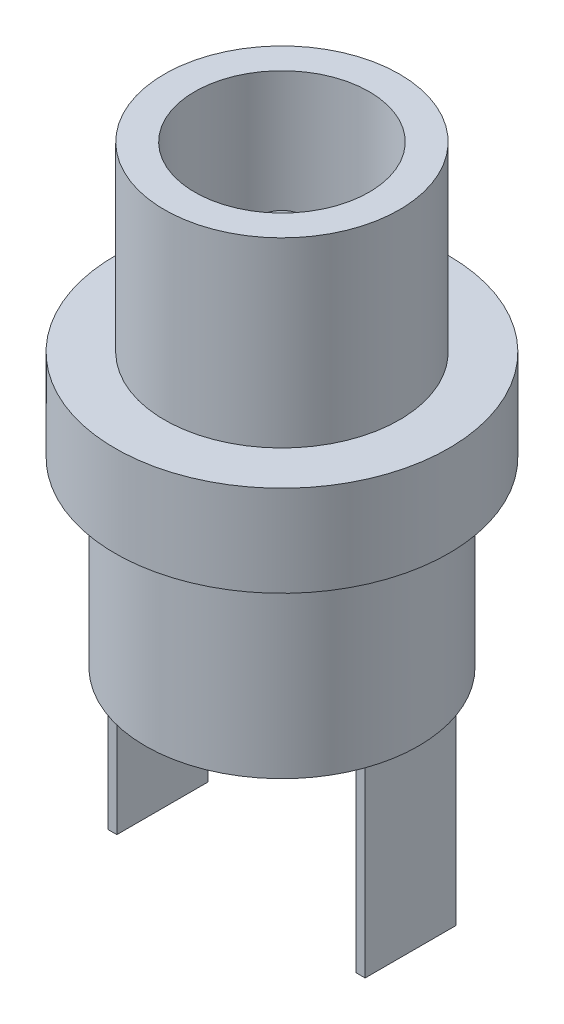
from build123d import *

# Parameters (mm, degrees)
SKIZZE2_W                       = 0.3
SKIZZE2_H                       = 3
SKIZZE2_W_2                     = 3
SKIZZE2_H_2                     = 0.3
AUFSATZ_LINEAR_AUSTRAGEN1_DEPTH = 6
VERRUNDUNG1_R                   = 0.75


with BuildPart() as part:
    # Skizze1 → Rotation1 (revolve)
    with BuildSketch(Plane.XY):
        Polygon((-3.875, 0), (-3.875, -6), (-5.5, -6), (-5.5, -9), (-4.5, -9), (-4.5, -15), (0, -15), (0, -2.3), (-1, -2.3), (-1, -10), (-2.875, -10), (-2.875, 0), align=None)
    revolve(axis=Axis((0, -15, 0), (0, 1, 0)))

    # Skizze2 → Aufsatz-Linear austragen1 (add)
    with BuildSketch(Plane.XZ.offset(15)):
        with Locations((-4.092640687, 0)):
            Rectangle(SKIZZE2_W, SKIZZE2_H)
        with Locations((4.092640687, 0)):
            Rectangle(SKIZZE2_W, SKIZZE2_H)
        with Locations((0, -4.092640687)):
            Rectangle(SKIZZE2_W_2, SKIZZE2_H_2)
    extrude(amount=AUFSATZ_LINEAR_AUSTRAGEN1_DEPTH)

    # Verrundung1
    verrundung1_edges = [part.edges().sort_by_distance(p)[0] for p in [
        (1, -2.3, 0),
    ]]
    fillet(verrundung1_edges, radius=VERRUNDUNG1_R)


solid = part.part
